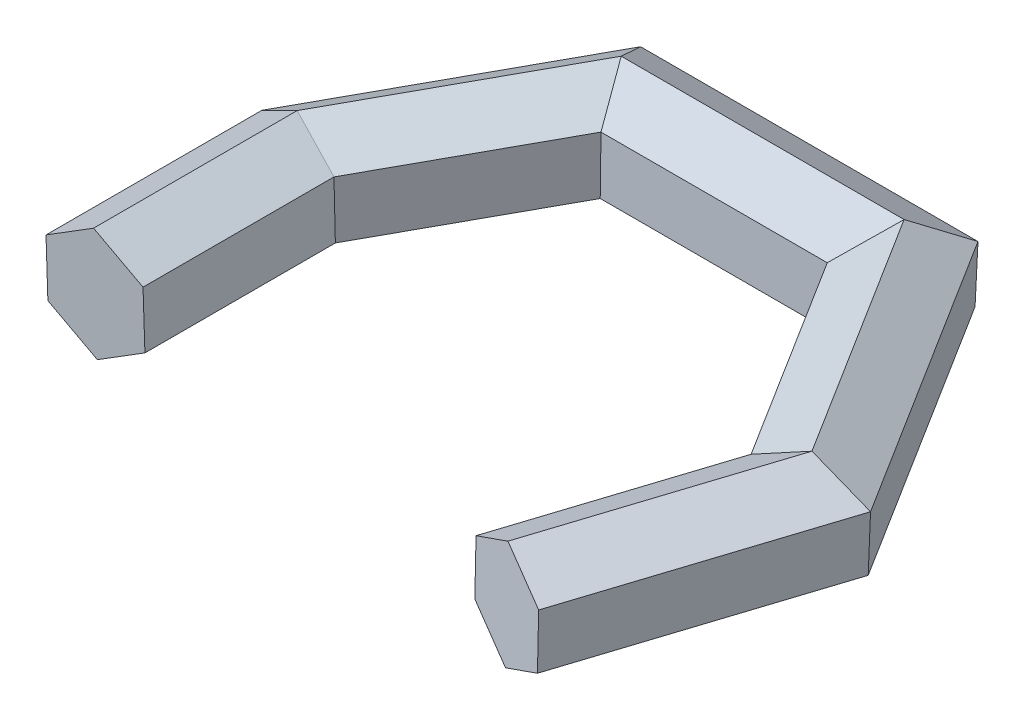
from build123d import *


with BuildPart() as part:
    # Sweep2: sweep along a path in Sketch3
    with BuildLine(Plane(origin=(0, 0, 0), x_dir=(1, 0, 0), z_dir=(0, 1, 0))) as sweep2_path:
        Line((0, 0), (0, 36.242190507))
        Line((0, 36.242190507), (20.360781184, 73.298812262))
        Line((20.360781184, 73.298812262), (70.448302897, 73.298812262))
        Line((70.448302897, 73.298812262), (97.837038373, 29.582176791))
        Line((97.837038373, 29.582176791), (84.672762234, -11.296364903))
    # Sketch1 → Sweep2 (sweep)
    with BuildSketch(Plane.XY):
        Polygon((8.824071359, -4.70486606), (8.486569209, 5.289436932), (-0.33750215, 9.994302992), (-8.824071359, 4.70486606), (-8.486569209, -5.289436932), (0.33750215, -9.994302992), align=None)
    sweep(path=sweep2_path.line, transition=Transition.RIGHT)


solid = part.part
